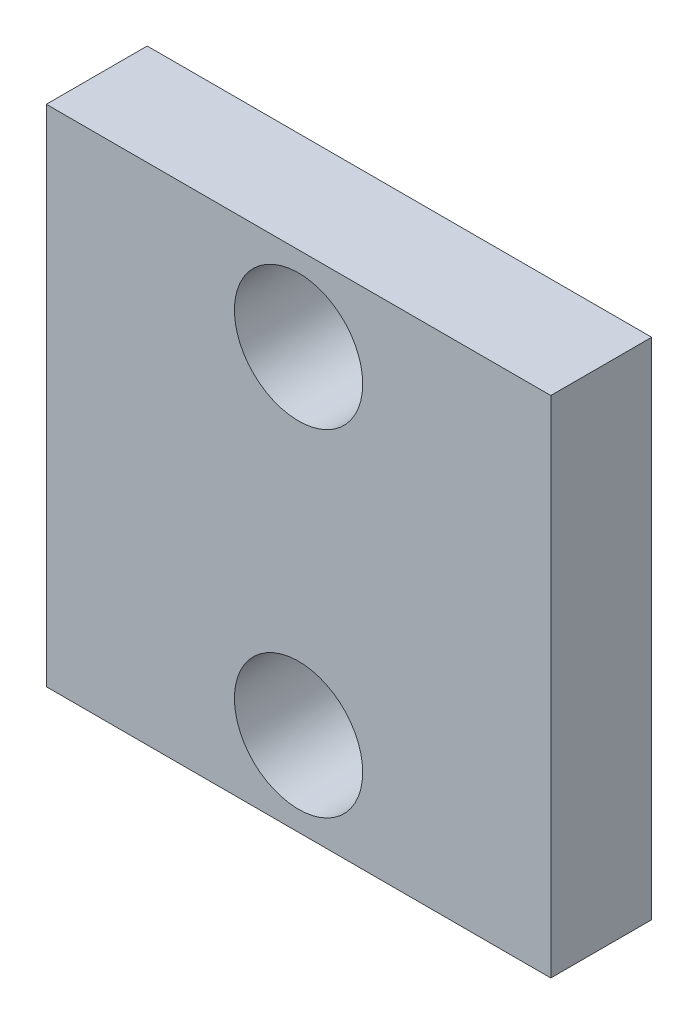
from build123d import *

# Parameters (mm, degrees)
ESQUISSE2_W        = 60
ESQUISSE2_H        = 60
ESQUISSE2_R        = 7.627282303
BOSS_EXTRU_3_DEPTH = 12


with BuildPart() as part:
    # Esquisse2 → Boss.-Extru.3 (new body)
    with BuildSketch(Plane.XY):
        Rectangle(ESQUISSE2_W, ESQUISSE2_H)
        with Locations((0, 20)):
            Circle(ESQUISSE2_R, mode=Mode.SUBTRACT)
        with Locations((0, -20)):
            Circle(ESQUISSE2_R, mode=Mode.SUBTRACT)
    extrude(amount=BOSS_EXTRU_3_DEPTH)


solid = part.part
